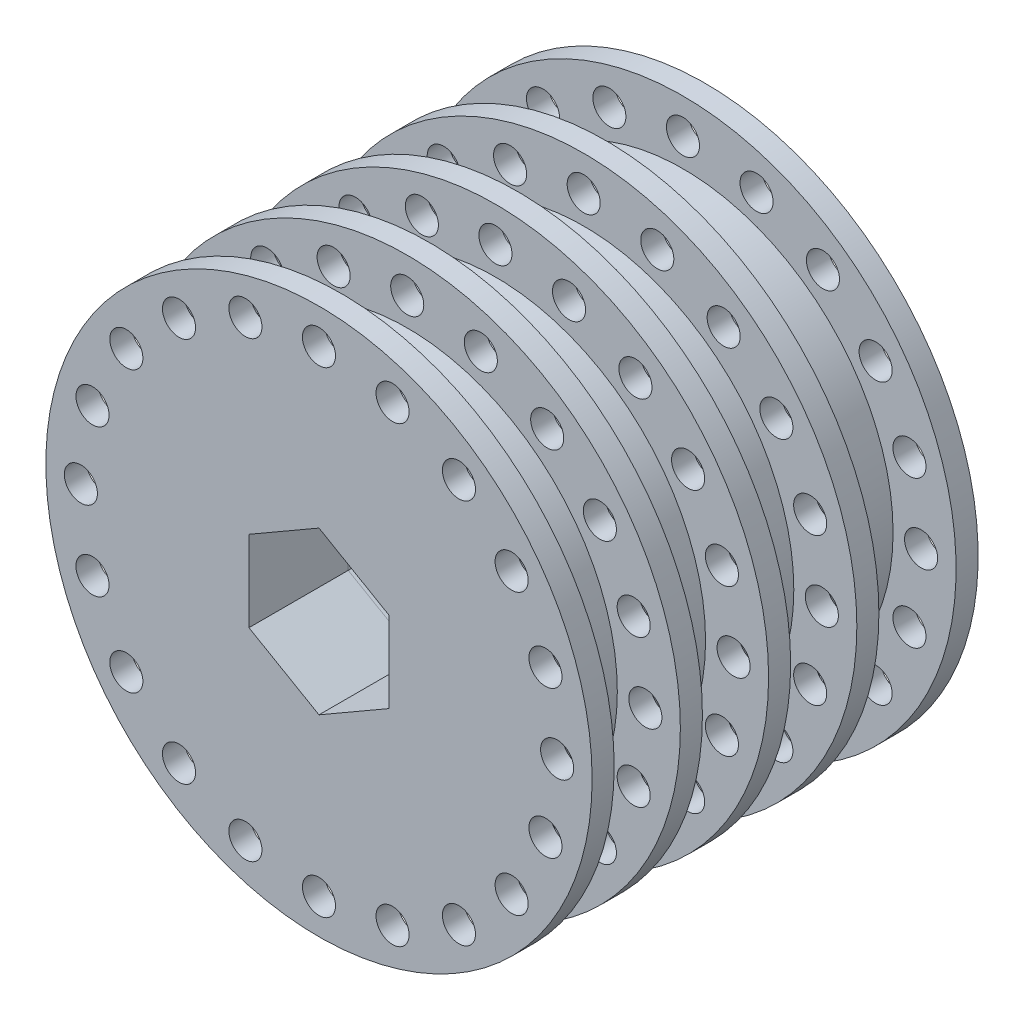
from build123d import *

# Parameters (mm, degrees)
SKETCH1_R           = 24.765
SKETCH1_R_2         = 1.5
BOSS_EXTRUDE1_DEPTH = 2
SKETCH1_3_R         = 19.05
BOSS_EXTRUDE2_DEPTH = 7
LPATTERN2_COUNT     = 4
LPATTERN2_PITCH     = 8
BOSS_EXTRUDE3_START = 2
SKETCH2_R           = 24.765
SKETCH2_R_2         = 1.5
BOSS_EXTRUDE3_DEPTH = 2
CUT_EXTRUDE1_DEPTH  = 50.513740012


with BuildPart() as part:
    # Sketch1 → Boss-Extrude1 (new body)
    with BuildSketch(Plane.XY):
        Circle(SKETCH1_R)
        with Locations((-12.690283597, -17.466676909)):
            Circle(SKETCH1_R_2, mode=Mode.SUBTRACT)
        with Locations((-17.466676909, -12.690283597)):
            Circle(SKETCH1_R_2, mode=Mode.SUBTRACT)
        with Locations((-6.671676909, -20.533310187)):
            Circle(SKETCH1_R_2, mode=Mode.SUBTRACT)
        with Locations((-20.533310187, -6.671676909)):
            Circle(SKETCH1_R_2, mode=Mode.SUBTRACT)
        with Locations((-21.59, 0)):
            Circle(SKETCH1_R_2, mode=Mode.SUBTRACT)
        with Locations((12.690283597, 17.466676909)):
            Circle(SKETCH1_R_2, mode=Mode.SUBTRACT)
        with Locations((0, -21.59)):
            Circle(SKETCH1_R_2, mode=Mode.SUBTRACT)
        with Locations((6.671676909, -20.533310187)):
            Circle(SKETCH1_R_2, mode=Mode.SUBTRACT)
        with Locations((12.690283597, -17.466676909)):
            Circle(SKETCH1_R_2, mode=Mode.SUBTRACT)
        with Locations((17.466676909, -12.690283597)):
            Circle(SKETCH1_R_2, mode=Mode.SUBTRACT)
        with Locations((20.533310187, -6.671676909)):
            Circle(SKETCH1_R_2, mode=Mode.SUBTRACT)
        with Locations((-20.533310187, 6.671676909)):
            Circle(SKETCH1_R_2, mode=Mode.SUBTRACT)
        with Locations((-17.466676909, 12.690283597)):
            Circle(SKETCH1_R_2, mode=Mode.SUBTRACT)
        with Locations((-12.690283597, 17.466676909)):
            Circle(SKETCH1_R_2, mode=Mode.SUBTRACT)
        with Locations((-6.671676909, 20.533310187)):
            Circle(SKETCH1_R_2, mode=Mode.SUBTRACT)
        with Locations((0, 21.59)):
            Circle(SKETCH1_R_2, mode=Mode.SUBTRACT)
        with Locations((21.59, 0)):
            Circle(SKETCH1_R_2, mode=Mode.SUBTRACT)
        with Locations((20.533310187, 6.671676909)):
            Circle(SKETCH1_R_2, mode=Mode.SUBTRACT)
        with Locations((6.671676909, 20.533310187)):
            Circle(SKETCH1_R_2, mode=Mode.SUBTRACT)
        with Locations((17.466676909, 12.690283597)):
            Circle(SKETCH1_R_2, mode=Mode.SUBTRACT)
    extrude(amount=BOSS_EXTRUDE1_DEPTH)

    # Sketch1_3 → Boss-Extrude2 (add)
    with BuildSketch(Plane.XY):
        Circle(SKETCH1_3_R)
    extrude(amount=-BOSS_EXTRUDE2_DEPTH)


with BuildPart() as lpattern2_1:
    # LPattern2: pattern copy
    add(part.part.moved(Location(Vector(0, 0, -1) * (1 * LPATTERN2_PITCH))))


with BuildPart() as lpattern2_2:
    # LPattern2: pattern copy
    add(part.part.moved(Location(Vector(0, 0, -1) * (2 * LPATTERN2_PITCH))))


with BuildPart() as lpattern2_3:
    # LPattern2: pattern copy
    add(part.part.moved(Location(Vector(0, 0, -1) * (3 * LPATTERN2_PITCH))))

    # Sketch2 → Boss-Extrude3 (add)
    with BuildSketch(Plane(origin=(0, 0, -31), x_dir=(-1, 0, 0), z_dir=(0, 0, -1)).offset(BOSS_EXTRUDE3_START)):
        Circle(SKETCH2_R)
        with Locations((-12.690283597, -17.466676909)):
            Circle(SKETCH2_R_2, mode=Mode.SUBTRACT)
        with Locations((-17.466676909, -12.690283597)):
            Circle(SKETCH2_R_2, mode=Mode.SUBTRACT)
        with Locations((-6.671676909, -20.533310187)):
            Circle(SKETCH2_R_2, mode=Mode.SUBTRACT)
        with Locations((0, -21.59)):
            Circle(SKETCH2_R_2, mode=Mode.SUBTRACT)
        with Locations((-20.533310187, -6.671676909)):
            Circle(SKETCH2_R_2, mode=Mode.SUBTRACT)
        with Locations((12.690283597, 17.466676909)):
            Circle(SKETCH2_R_2, mode=Mode.SUBTRACT)
        with Locations((6.671676909, -20.533310187)):
            Circle(SKETCH2_R_2, mode=Mode.SUBTRACT)
        with Locations((12.690283597, -17.466676909)):
            Circle(SKETCH2_R_2, mode=Mode.SUBTRACT)
        with Locations((17.466676909, -12.690283597)):
            Circle(SKETCH2_R_2, mode=Mode.SUBTRACT)
        with Locations((20.533310187, -6.671676909)):
            Circle(SKETCH2_R_2, mode=Mode.SUBTRACT)
        with Locations((21.59, 0)):
            Circle(SKETCH2_R_2, mode=Mode.SUBTRACT)
        with Locations((-21.59, 0)):
            Circle(SKETCH2_R_2, mode=Mode.SUBTRACT)
        with Locations((-20.533310187, 6.671676909)):
            Circle(SKETCH2_R_2, mode=Mode.SUBTRACT)
        with Locations((-17.466676909, 12.690283597)):
            Circle(SKETCH2_R_2, mode=Mode.SUBTRACT)
        with Locations((-12.690283597, 17.466676909)):
            Circle(SKETCH2_R_2, mode=Mode.SUBTRACT)
        with Locations((-6.671676909, 20.533310187)):
            Circle(SKETCH2_R_2, mode=Mode.SUBTRACT)
        with Locations((0, 21.59)):
            Circle(SKETCH2_R_2, mode=Mode.SUBTRACT)
        with Locations((20.533310187, 6.671676909)):
            Circle(SKETCH2_R_2, mode=Mode.SUBTRACT)
        with Locations((6.671676909, 20.533310187)):
            Circle(SKETCH2_R_2, mode=Mode.SUBTRACT)
        with Locations((17.466676909, 12.690283597)):
            Circle(SKETCH2_R_2, mode=Mode.SUBTRACT)
    extrude(amount=-BOSS_EXTRUDE3_DEPTH)


with BuildPart() as cut_extrude1_tool:
    # Sketch3 → Cut-Extrude1 (new, through all)
    with BuildSketch(Plane(origin=(0, 0, -33), x_dir=(-1, 0, 0), z_dir=(0, 0, -1))):
        Polygon((6.35, 3.666174209), (0, 7.332348419), (-6.35, 3.666174209), (-6.35, -3.666174209), (0, -7.332348419), (6.35, -3.666174209), align=None)
    extrude(amount=-CUT_EXTRUDE1_DEPTH)


with BuildPart() as part_1:
    add(part.part)

    # Cut-Extrude1: cut by cut_extrude1_tool
    add(cut_extrude1_tool.part, mode=Mode.SUBTRACT)


with BuildPart() as lpattern2_1_1:
    add(lpattern2_1.part)

    # Cut-Extrude1: cut by cut_extrude1_tool
    add(cut_extrude1_tool.part, mode=Mode.SUBTRACT)


with BuildPart() as lpattern2_2_1:
    add(lpattern2_2.part)

    # Cut-Extrude1: cut by cut_extrude1_tool
    add(cut_extrude1_tool.part, mode=Mode.SUBTRACT)


with BuildPart() as lpattern2_3_1:
    add(lpattern2_3.part)

    # Cut-Extrude1: cut by cut_extrude1_tool
    add(cut_extrude1_tool.part, mode=Mode.SUBTRACT)


solid = Compound([part_1.part, lpattern2_1_1.part, lpattern2_2_1.part, lpattern2_3_1.part])
